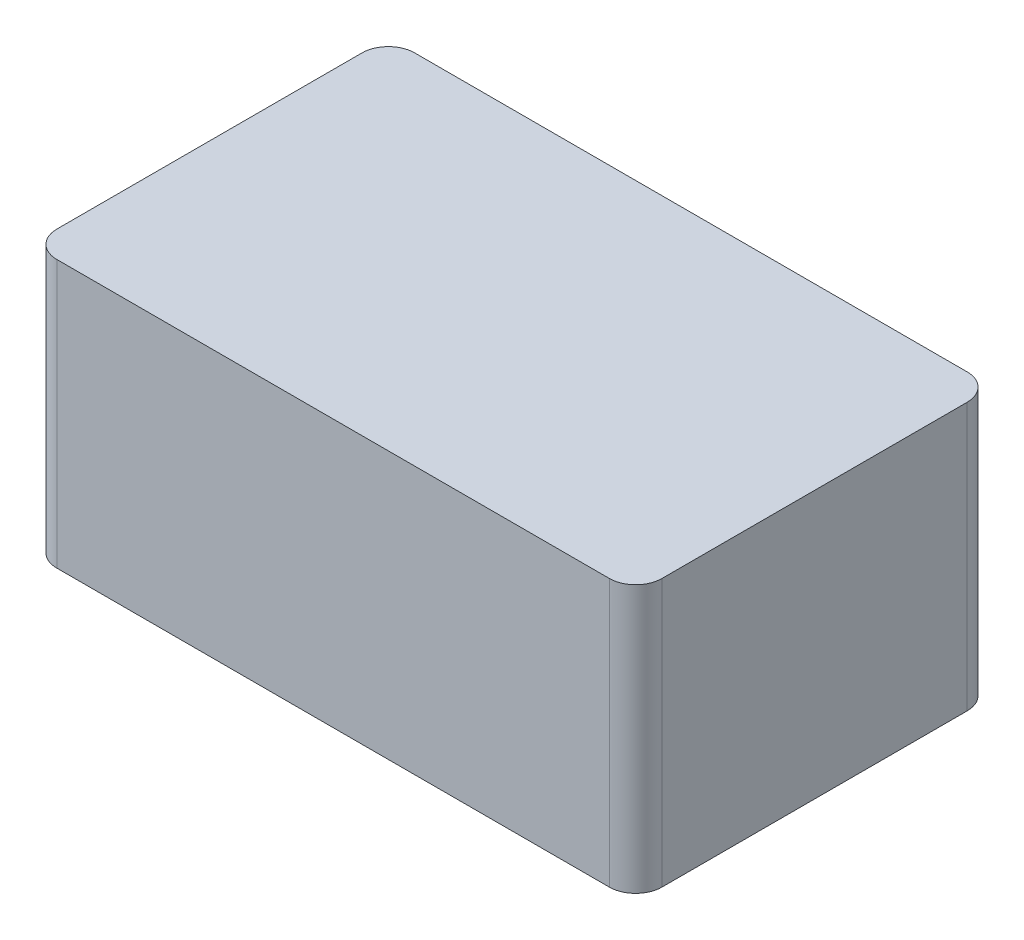
from build123d import *

# Parameters (mm, degrees)
SKETCH2_W           = 115
SKETCH2_H           = 68
BOSS_EXTRUDE1_DEPTH = 50.8
FILLET1_R           = 5


with BuildPart() as part:
    # Sketch2 → Boss-Extrude1 (new body)
    with BuildSketch(Plane(origin=(0, 0, 0), x_dir=(1, 0, 0), z_dir=(0, 1, 0))):
        with Locations((27.451219512, -11.317073171)):
            Rectangle(SKETCH2_W, SKETCH2_H)
    extrude(amount=BOSS_EXTRUDE1_DEPTH)

    # Fillet1
    fillet1_edges = [part.edges().sort_by_distance(p)[0] for p in [
        (-30.048780488, 25.4, -22.682926829),
        (84.951219512, 25.4, -22.682926829),
        (84.951219512, 25.4, 45.317073171),
        (-30.048780488, 25.4, 45.317073171),
    ]]
    fillet(fillet1_edges, radius=FILLET1_R)


solid = part.part
